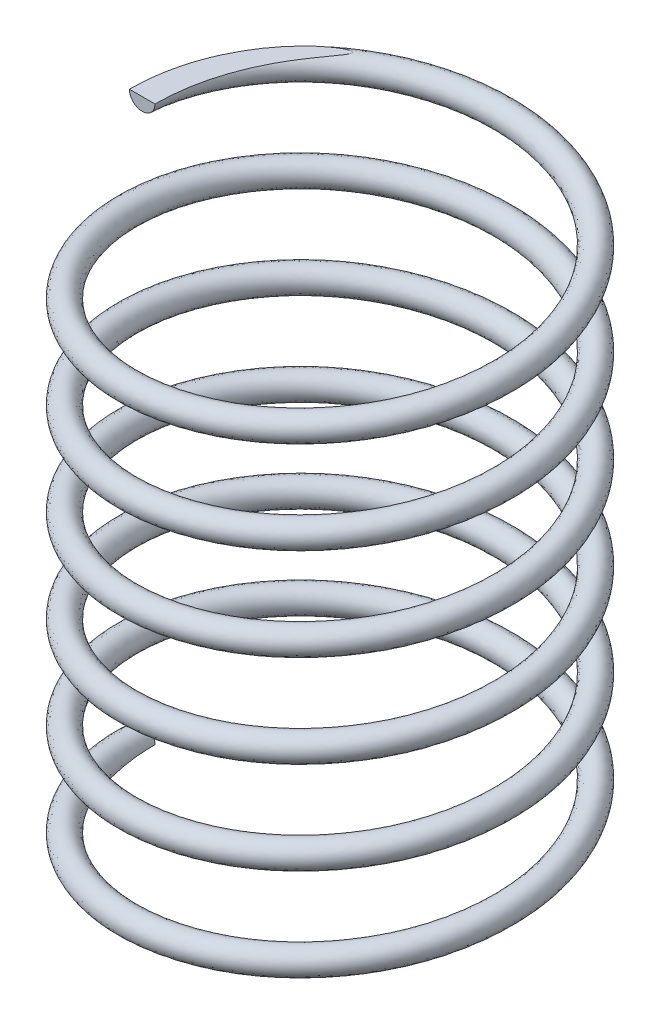
from build123d import *

# Parameters (mm, degrees)
SWEEP2_PITCH       = 2.166666667
SWEEP2_HEIGHT      = 13
SWEEP2_RADIUS      = 4.4
SWEEP2_START_ANGLE = -90
SKETCH5_R          = 0.3


with BuildPart() as part:
    # Sweep2: sweep along a helix
    with BuildLine() as sweep2_path:
        add(Helix(SWEEP2_PITCH, SWEEP2_HEIGHT, SWEEP2_RADIUS, center=(0, 0, 0), direction=(0, -1, 0), mode=Mode.PRIVATE).rotate(Axis((0, 0, 0), (0, -1, 0)), SWEEP2_START_ANGLE))
    # Sketch5 → Sweep2 (sweep)
    with BuildSketch(Plane.XY):
        with Locations((-4.4, 0)):
            Circle(SKETCH5_R)
    sweep(path=sweep2_path.line, is_frenet=True)

    # SurfaceCut5
    split(bisect_by=Plane(origin=(0, 0, 0), x_dir=(1, 0, 0), z_dir=(0, 1, 0)), keep=Keep.BOTTOM)

    # SurfaceCut6
    split(bisect_by=Plane(origin=(0, -13, 0), x_dir=(1, 0, 0), z_dir=(0, 1, 0)), keep=Keep.TOP)


solid = part.part
